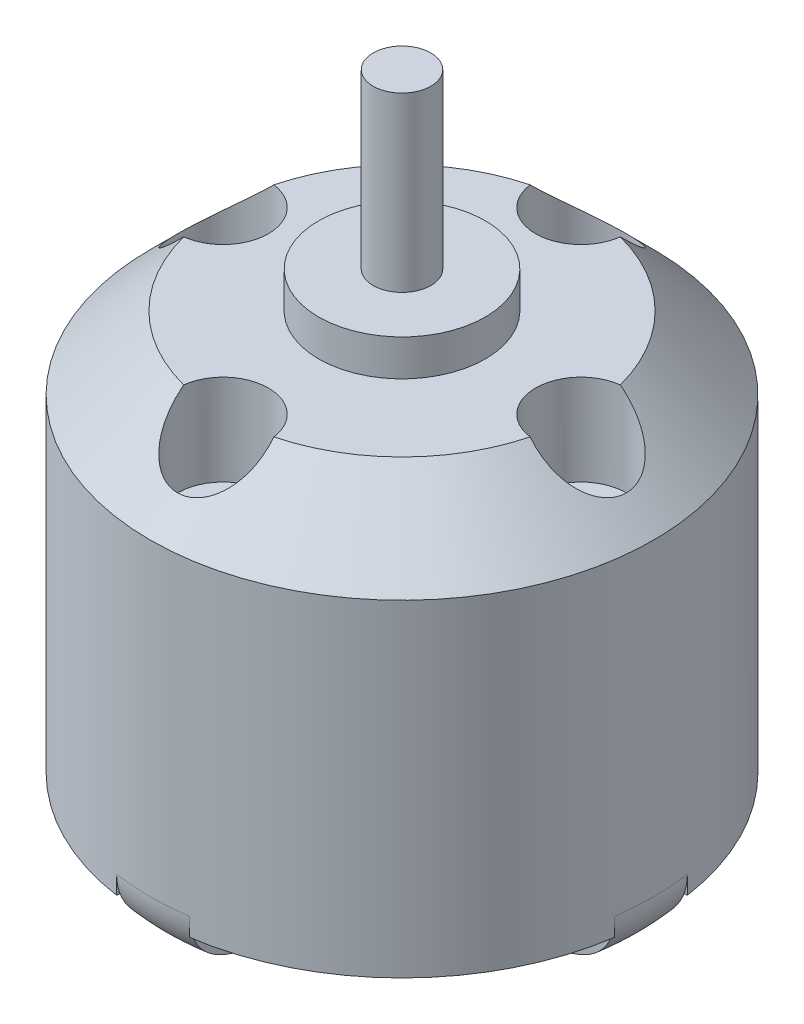
from build123d import *

# Parameters (mm, degrees)
SKETCH1_R           = 13.85
BOSS_EXTRUDE1_DEPTH = 26
SKETCH2_R           = 13.85
SKETCH2_R_2         = 4.5875
CUT_EXTRUDE1_DEPTH  = 2
SKETCH3_R           = 1.5875
BOSS_EXTRUDE2_DEPTH = 9.5
CHAMFER1_SIZE       = 4
SKETCH5_R           = 2.5
CUT_EXTRUDE2_DEPTH  = 5
SKETCH6_R           = 0.8
CUT_EXTRUDE3_DEPTH  = 5
FILLET1_R           = 3
CUT_EXTRUDE4_DEPTH  = 3
BOSS_EXTRUDE3_DEPTH = 1
SKETCH11_R          = 3.5
BOSS_EXTRUDE4_DEPTH = 0.5
SKETCH12_R          = 1.5875
BOSS_EXTRUDE5_DEPTH = 1
SKETCH13_R          = 1.25
CUT_EXTRUDE5_DEPTH  = 5


with BuildPart() as part:
    # Sketch1 → Boss-Extrude1 (new body)
    with BuildSketch(Plane(origin=(0, 0, 0), x_dir=(1, 0, 0), z_dir=(0, 1, 0))):
        Circle(SKETCH1_R)
    extrude(amount=BOSS_EXTRUDE1_DEPTH)

    # Sketch2 → Cut-Extrude1 (cut)
    with BuildSketch(Plane(origin=(0, 26, 0), x_dir=(-1, 0, 0), z_dir=(0, 1, 0))):
        Circle(SKETCH2_R)
        Circle(SKETCH2_R_2, mode=Mode.SUBTRACT)
    extrude(amount=-CUT_EXTRUDE1_DEPTH, mode=Mode.SUBTRACT)

    # Sketch3 → Boss-Extrude2 (add)
    with BuildSketch(Plane(origin=(0, 26, 0), x_dir=(1, 0, 0), z_dir=(0, 1, 0))):
        Circle(SKETCH3_R)
    extrude(amount=BOSS_EXTRUDE2_DEPTH)

    # Chamfer1
    chamfer1_edges = [part.edges().sort_by_distance(p)[0] for p in [
        (-13.85, 24, 0),
    ]]
    chamfer(chamfer1_edges, length=CHAMFER1_SIZE)

    # Sketch5 → Cut-Extrude2 (cut)
    with BuildSketch(Plane(origin=(0, 24, 0), x_dir=(1, 0, 0), z_dir=(0, 1, 0))):
        with Locations((-9.85, 0)):
            Circle(SKETCH5_R)
        with Locations((0, 9.85)):
            Circle(SKETCH5_R)
        with Locations((9.85, 0)):
            Circle(SKETCH5_R)
        with Locations((0, -9.85)):
            Circle(SKETCH5_R)
    extrude(amount=-CUT_EXTRUDE2_DEPTH, mode=Mode.SUBTRACT)

    # Sketch6 → Cut-Extrude3 (cut)
    with BuildSketch(Plane.XZ):
        with Locations((0, -8)):
            Circle(SKETCH6_R)
        with Locations((9.5, 0)):
            Circle(SKETCH6_R)
        with Locations((0, 8)):
            Circle(SKETCH6_R)
        with Locations((-9.5, 0)):
            Circle(SKETCH6_R)
    extrude(amount=-CUT_EXTRUDE3_DEPTH, mode=Mode.SUBTRACT)

    # Fillet1
    fillet1_edges = [part.edges().sort_by_distance(p)[0] for p in [
        (-13.85, 0, 0),
    ]]
    fillet(fillet1_edges, radius=FILLET1_R)

    # Sketch7 → Cut-Extrude4 (cut)
    with BuildSketch(Plane(origin=(0, 0, 0), x_dir=(1, 0, 0), z_dir=(0, 1, 0))):
        with BuildLine():
            ThreePointArc((-13.704834913, 2), (-5.089296712, 5.089296712), (-2, 13.704834913))
            ThreePointArc((-2, 13.704834913), (-9.793428919, 9.793428919), (-13.704834913, 2))
        make_face()
        with BuildLine():
            ThreePointArc((-13.704834913, -2), (-9.793428919, -9.793428919), (-2, -13.704834913))
            ThreePointArc((-2, -13.704834913), (-5.089296712, -5.089296712), (-13.704834913, -2))
        make_face()
        with BuildLine():
            ThreePointArc((2, -13.704834913), (9.793428919, -9.793428919), (13.704834913, -2))
            ThreePointArc((13.704834913, -2), (5.089296712, -5.089296712), (2, -13.704834913))
        make_face()
        with BuildLine():
            ThreePointArc((13.704834913, 2), (9.793428919, 9.793428919), (2, 13.704834913))
            ThreePointArc((2, 13.704834913), (5.089296712, 5.089296712), (13.704834913, 2))
        make_face()
    extrude(amount=CUT_EXTRUDE4_DEPTH, mode=Mode.SUBTRACT)

    # Sketch10 → Boss-Extrude3 (add)
    with BuildSketch(Plane.XZ.offset(-3)):
        with BuildLine():
            ThreePointArc((-2, 13.704834913), (-9.793428919, 9.793428919), (-13.704834913, 2))
            ThreePointArc((-13.704834913, 2), (-13.203607209, 1.963159056), (-12.701203563, 1.949853343))
            ThreePointArc((-12.701203563, 1.949853343), (-9.086322138, 9.086322138), (-1.949853343, 12.701203563))
            ThreePointArc((-1.949853343, 12.701203563), (-1.963159056, 13.203607209), (-2, 13.704834913))
        make_face()
        with BuildLine():
            ThreePointArc((2, 13.704834913), (1.963159056, 13.203607209), (1.949853343, 12.701203563))
            ThreePointArc((1.949853343, 12.701203563), (9.086322138, 9.086322138), (12.701203563, 1.949853343))
            ThreePointArc((12.701203563, 1.949853343), (13.203607209, 1.963159056), (13.704834913, 2))
            ThreePointArc((13.704834913, 2), (9.793428919, 9.793428919), (2, 13.704834913))
        make_face()
        with BuildLine():
            ThreePointArc((13.704834913, -2), (13.203607209, -1.963159056), (12.701203563, -1.949853343))
            ThreePointArc((12.701203563, -1.949853343), (9.086322138, -9.086322138), (1.949853343, -12.701203563))
            ThreePointArc((1.949853343, -12.701203563), (1.963159056, -13.203607209), (2, -13.704834913))
            ThreePointArc((2, -13.704834913), (9.793428919, -9.793428919), (13.704834913, -2))
        make_face()
        with BuildLine():
            ThreePointArc((-2, -13.704834913), (-1.963159056, -13.203607209), (-1.949853343, -12.701203563))
            ThreePointArc((-1.949853343, -12.701203563), (-9.086322138, -9.086322138), (-12.701203563, -1.949853343))
            ThreePointArc((-12.701203563, -1.949853343), (-13.203607209, -1.963159056), (-13.704834913, -2))
            ThreePointArc((-13.704834913, -2), (-9.793428919, -9.793428919), (-2, -13.704834913))
        make_face()
    extrude(amount=BOSS_EXTRUDE3_DEPTH)

    # Sketch11 → Boss-Extrude4 (add)
    with BuildSketch(Plane.XZ):
        Circle(SKETCH11_R)
    extrude(amount=BOSS_EXTRUDE4_DEPTH)

    # Sketch12 → Boss-Extrude5 (add)
    with BuildSketch(Plane.XZ.offset(0.5)):
        Circle(SKETCH12_R)
    extrude(amount=BOSS_EXTRUDE5_DEPTH)

    # Sketch13 → Cut-Extrude5 (cut)
    with BuildSketch(Plane.XZ):
        with Locations((9.5, 0)):
            Circle(SKETCH13_R)
        with Locations((0, -8)):
            Circle(SKETCH13_R)
        with Locations((-9.5, 0)):
            Circle(SKETCH13_R)
        with Locations((0, 8)):
            Circle(SKETCH13_R)
    extrude(amount=-CUT_EXTRUDE5_DEPTH, mode=Mode.SUBTRACT)


solid = part.part
